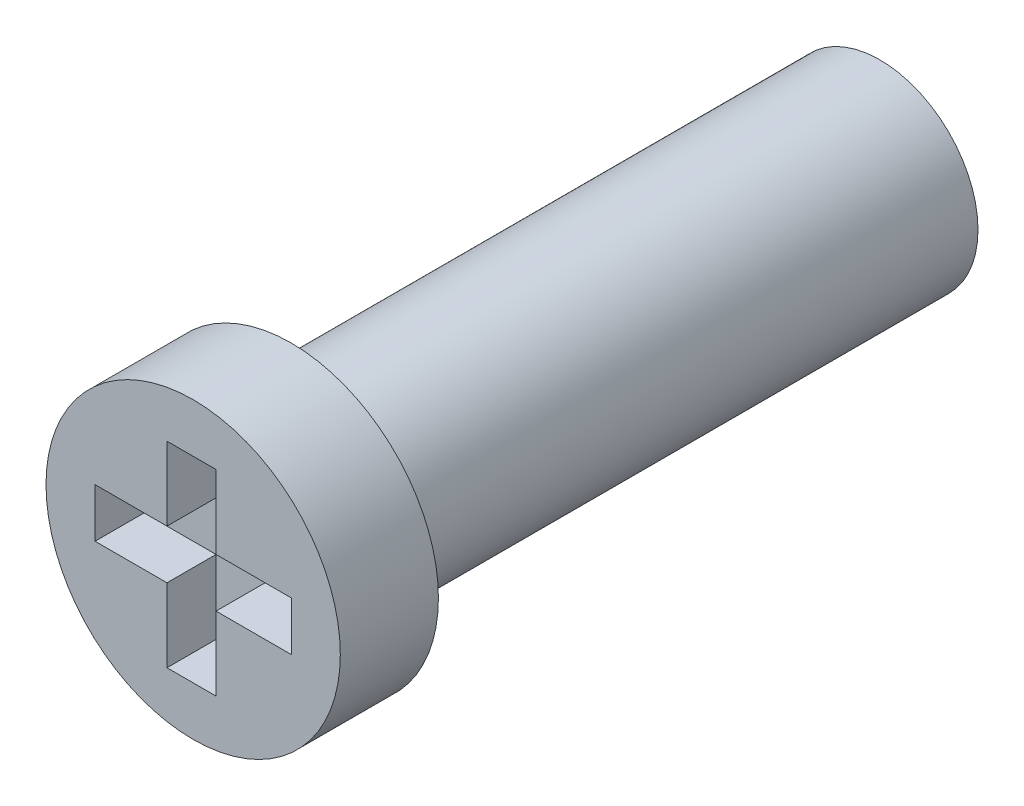
from build123d import *

# Parameters (mm, degrees)
SZKIC1_R                    = 2
DODANIE_WYCI_GNI_CIE1_DEPTH = 12
SZKIC2_R                    = 3
DODANIE_WYCI_GNI_CIE2_DEPTH = 2
WYTNIJ_WYCI_GNI_CIE1_DEPTH  = 1


with BuildPart() as part:
    # Szkic1 → Dodanie-wyciągnięcie1 (new body)
    with BuildSketch(Plane.XY):
        Circle(SZKIC1_R)
    extrude(amount=DODANIE_WYCI_GNI_CIE1_DEPTH)

    # Szkic2 → Dodanie-wyciągnięcie2 (add)
    with BuildSketch(Plane.XY.offset(12)):
        Circle(SZKIC2_R)
    extrude(amount=DODANIE_WYCI_GNI_CIE2_DEPTH)

    # Szkic3 → Wytnij-wyciągnięcie1 (cut)
    with BuildSketch(Plane.XY.offset(14)):
        Polygon((0.466528249, 0.5), (2, 0.5), (2, -0.5), (0.466528249, -0.5), (0.466528249, -2), (-0.533471751, -2), (-0.533471751, -0.5), (-2, -0.5), (-2, 0.5), (-0.533471751, 0.5), (-0.533471751, 2), (0.466528249, 2), align=None)
    extrude(amount=-WYTNIJ_WYCI_GNI_CIE1_DEPTH, mode=Mode.SUBTRACT)


solid = part.part
